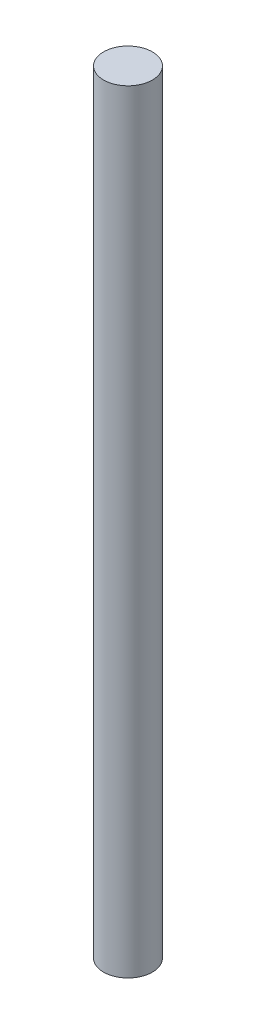
from build123d import *

# Parameters (mm, degrees)
SKETCH1_R           = 914.4
BOSS_EXTRUDE1_DEPTH = 28956


with BuildPart() as part:
    # Sketch1 → Boss-Extrude1 (new body)
    with BuildSketch(Plane(origin=(0, 0, 0), x_dir=(1, 0, 0), z_dir=(0, 1, 0))):
        Circle(SKETCH1_R)
    extrude(amount=BOSS_EXTRUDE1_DEPTH)


solid = part.part
